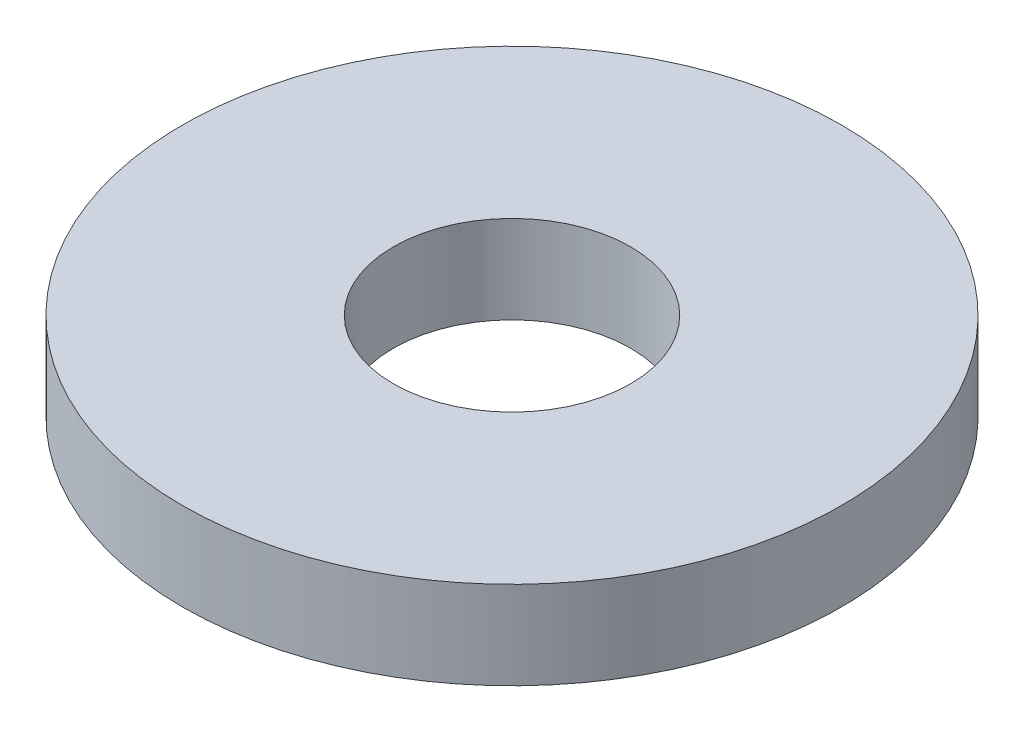
from build123d import *

# Parameters (mm, degrees)
SKETCH1_R           = 7.5
SKETCH1_R_2         = 2.7
BOSS_EXTRUDE1_DEPTH = 2


with BuildPart() as part:
    # Sketch1 → Boss-Extrude1 (new body)
    with BuildSketch(Plane(origin=(0, 0, 0), x_dir=(1, 0, 0), z_dir=(0, 1, 0))):
        Circle(SKETCH1_R)
        Circle(SKETCH1_R_2, mode=Mode.SUBTRACT)
    extrude(amount=BOSS_EXTRUDE1_DEPTH)


solid = part.part
